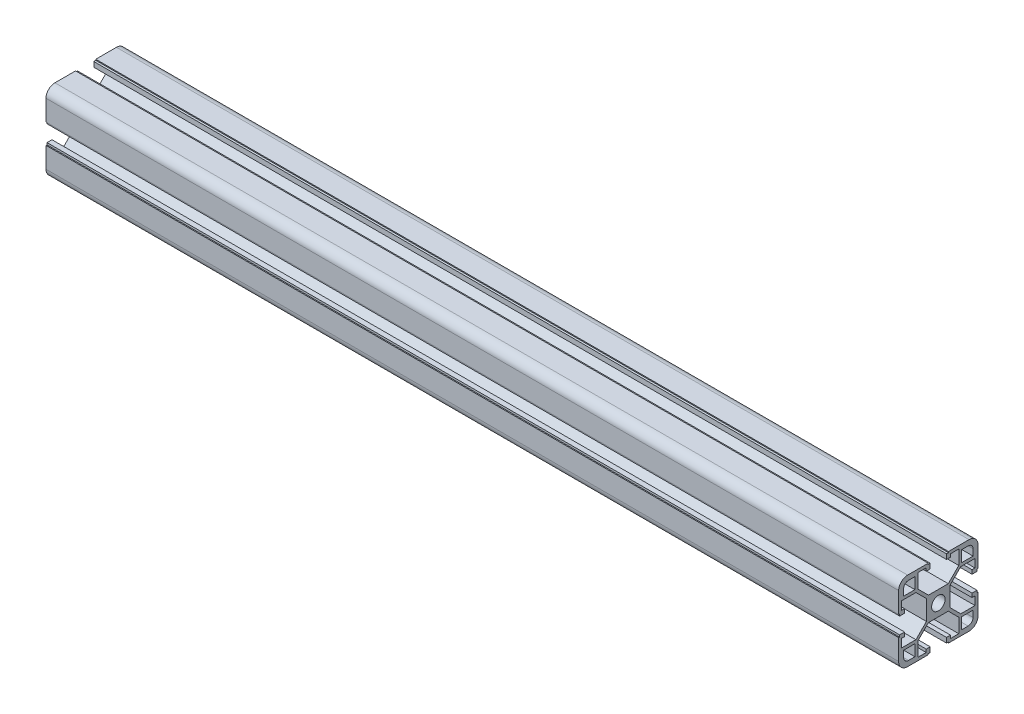
from build123d import *

# Parameters (mm, degrees)
SKETCH1_R                 = 3.4
F_40_X_40L_X_R4_5_1_DEPTH = 430
SKETCH_2_R                = 2.5
CUT_EXTRUDE_1_DEPTH       = 269.747093008


with BuildPart() as part:
    # Sketch1 → 铝型材 40 X 40L X R4.5(1) (new body)
    with BuildSketch(Plane(origin=(-165, 0, 0), x_dir=(0, 0, -1), z_dir=(1, 0, 0))):
        with BuildLine():
            Line((-5.1, 20), (-5.1, 19.5))
            Line((-5.1, 19.5), (-4.1, 19.5))
            Line((-4.1, 19.5), (-4.1, 17))
            Line((-4.1, 17), (-6.1, 17))
            Line((-6.1, 17), (-6.1, 18.5))
            Line((-6.1, 18.5), (-10.3, 18.5))
            Line((-10.3, 18.5), (-10.3, 11.3))
            Line((-10.3, 11.3), (-5, 6))
            Line((-5, 6), (5, 6))
            Line((5, 6), (10.3, 11.3))
            Line((10.3, 11.3), (10.3, 18.5))
            Line((10.3, 18.5), (6.1, 18.5))
            Line((6.1, 18.5), (6.1, 17))
            Line((6.1, 17), (4.1, 17))
            Line((4.1, 17), (4.1, 19.5))
            Line((4.1, 19.5), (5.1, 19.5))
            Line((5.1, 19.5), (5.1, 20))
            Line((5.1, 20), (15.5, 20))
            ThreePointArc((15.5, 20), (18.681980515, 18.681980515), (20, 15.5))
            Line((20, 15.5), (20, 5.1))
            Line((20, 5.1), (19.5, 5.1))
            Line((19.5, 5.1), (19.5, 4.1))
            Line((19.5, 4.1), (17, 4.1))
            Line((17, 4.1), (17, 6.1))
            Line((17, 6.1), (18.5, 6.1))
            Line((18.5, 6.1), (18.5, 10.3))
            Line((18.5, 10.3), (11.3, 10.3))
            Line((11.3, 10.3), (6, 5))
            Line((6, 5), (6, -5))
            Line((6, -5), (11.3, -10.3))
            Line((11.3, -10.3), (18.5, -10.3))
            Line((18.5, -10.3), (18.5, -6.1))
            Line((18.5, -6.1), (17, -6.1))
            Line((17, -6.1), (17, -4.1))
            Line((17, -4.1), (19.5, -4.1))
            Line((19.5, -4.1), (19.5, -5.1))
            Line((19.5, -5.1), (20, -5.1))
            Line((20, -5.1), (20, -15.5))
            ThreePointArc((20, -15.5), (18.681980515, -18.681980515), (15.5, -20))
            Line((15.5, -20), (5.1, -20))
            Line((5.1, -20), (5.1, -19.5))
            Line((5.1, -19.5), (4.1, -19.5))
            Line((4.1, -19.5), (4.1, -17))
            Line((4.1, -17), (6.1, -17))
            Line((6.1, -17), (6.1, -18.5))
            Line((6.1, -18.5), (10.3, -18.5))
            Line((10.3, -18.5), (10.3, -11.3))
            Line((10.3, -11.3), (5, -6))
            Line((5, -6), (-5, -6))
            Line((-5, -6), (-10.3, -11.3))
            Line((-10.3, -11.3), (-10.3, -18.5))
            Line((-10.3, -18.5), (-6.1, -18.5))
            Line((-6.1, -18.5), (-6.1, -17))
            Line((-6.1, -17), (-4.1, -17))
            Line((-4.1, -17), (-4.1, -19.5))
            Line((-4.1, -19.5), (-5.1, -19.5))
            Line((-5.1, -19.5), (-5.1, -20))
            Line((-5.1, -20), (-15.5, -20))
            ThreePointArc((-15.5, -20), (-18.681980515, -18.681980515), (-20, -15.5))
            Line((-20, -15.5), (-20, -5.1))
            Line((-20, -5.1), (-19.5, -5.1))
            Line((-19.5, -5.1), (-19.5, -4.1))
            Line((-19.5, -4.1), (-17, -4.1))
            Line((-17, -4.1), (-17, -6.1))
            Line((-17, -6.1), (-18.5, -6.1))
            Line((-18.5, -6.1), (-18.5, -10.3))
            Line((-18.5, -10.3), (-11.3, -10.3))
            Line((-11.3, -10.3), (-6, -5))
            Line((-6, -5), (-6, 5))
            Line((-6, 5), (-11.3, 10.3))
            Line((-11.3, 10.3), (-18.5, 10.3))
            Line((-18.5, 10.3), (-18.5, 6.1))
            Line((-18.5, 6.1), (-17, 6.1))
            Line((-17, 6.1), (-17, 4.1))
            Line((-17, 4.1), (-19.5, 4.1))
            Line((-19.5, 4.1), (-19.5, 5.1))
            Line((-19.5, 5.1), (-20, 5.1))
            Line((-20, 5.1), (-20, 15.5))
            ThreePointArc((-20, 15.5), (-18.681980515, 18.681980515), (-15.5, 20))
            Line((-15.5, 20), (-5.1, 20))
        make_face()
        Circle(SKETCH1_R, mode=Mode.SUBTRACT)
        with BuildLine():
            Line((11.8, 17.5), (15, 17.5))
            ThreePointArc((15, 17.5), (16.767766953, 16.767766953), (17.5, 15))
            Line((17.5, 15), (17.5, 11.8))
            Line((17.5, 11.8), (11.8, 11.8))
            Line((11.8, 11.8), (11.8, 17.5))
        make_face(mode=Mode.SUBTRACT)
        with BuildLine():
            Line((-15, 17.5), (-11.8, 17.5))
            Line((-11.8, 17.5), (-11.8, 11.8))
            Line((-11.8, 11.8), (-17.5, 11.8))
            Line((-17.5, 11.8), (-17.5, 15))
            ThreePointArc((-17.5, 15), (-16.767766953, 16.767766953), (-15, 17.5))
        make_face(mode=Mode.SUBTRACT)
        with BuildLine():
            Line((-17.5, -11.8), (-11.8, -11.8))
            Line((-11.8, -11.8), (-11.8, -17.5))
            Line((-11.8, -17.5), (-15, -17.5))
            ThreePointArc((-15, -17.5), (-16.767766953, -16.767766953), (-17.5, -15))
            Line((-17.5, -15), (-17.5, -11.8))
        make_face(mode=Mode.SUBTRACT)
        with BuildLine():
            Line((11.8, -11.8), (17.5, -11.8))
            Line((17.5, -11.8), (17.5, -15))
            ThreePointArc((17.5, -15), (16.767766953, -16.767766953), (15, -17.5))
            Line((15, -17.5), (11.8, -17.5))
            Line((11.8, -17.5), (11.8, -11.8))
        make_face(mode=Mode.SUBTRACT)
    extrude(amount=F_40_X_40L_X_R4_5_1_DEPTH)

    # 草图2 → 切除-拉伸1 (cut, through all)
    with BuildSketch(Plane(origin=(0, 20, 0), x_dir=(1, 0, 0), z_dir=(0, 1, 0))):
        with Locations(Location((-1, 0, 0), (0, 0, 270))):
            Circle(SKETCH_2_R)
        with Locations(Location((108, 0, 0), (0, 0, 270))):
            Circle(SKETCH_2_R)
    extrude(amount=-CUT_EXTRUDE_1_DEPTH, mode=Mode.SUBTRACT)


solid = part.part
